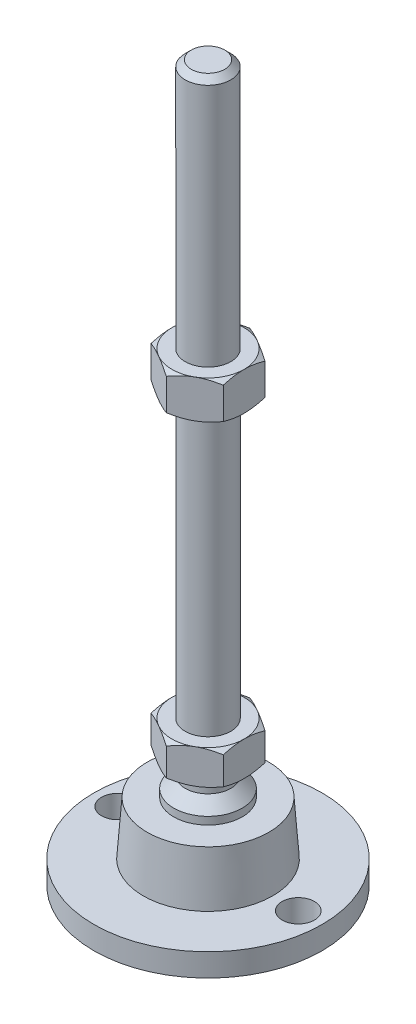
from build123d import *

# Parameters (mm, degrees)
EXTRUDE_1_DEPTH     = 9
EXTRUDE_2_DEPTH     = 10
SKETCH_5_R          = 4.25
CUT_EXTRUDE_1_DEPTH = 7


with BuildPart() as part:
    # Эскиз1 → Повернуть1 (revolve)
    with BuildSketch(Plane.XY, mode=Mode.PRIVATE) as revolve_1_sk:
        Polygon((0, 0), (-30, 0), (-30, 6), (-17, 6), (-16, 20), (-9, 20), (-9, 22), (-6, 25), (-6, 29), (-6, 38), (-6, 186.4), (-4.4, 188), (0, 188), align=None)
    revolve(revolve_1_sk.sketch.rotate(Axis((0, 0, 0), (0, 1, 0)), 180), axis=Axis((0, 0, 0), (0, 1, 0)))  # turned: the seam where the file's is

    # Эскиз2 → Бобышка-Вытянуть1 (add)
    with BuildSketch(Plane(origin=(0, 29, 0), x_dir=(1, 0, 0), z_dir=(0, 1, 0))):
        Polygon((0, 10.969655115), (-9.5, 5.484827557), (-9.5, -5.484827557), (0, -10.969655115), (9.5, -5.484827557), (9.5, 5.484827557), align=None)
    extrude(amount=EXTRUDE_1_DEPTH)

    # Эскиз3 → Бобышка-Вытянуть2 (add)
    with BuildSketch(Plane(origin=(0, 112.2, 0), x_dir=(1, 0, 0), z_dir=(0, 1, 0))):
        Polygon((9.5, 5.484827557), (0, 10.969655115), (-9.5, 5.484827557), (-9.5, -5.484827557), (0, -10.969655115), (9.5, -5.484827557), align=None)
    extrude(amount=EXTRUDE_2_DEPTH)

    # Эскиз4 → Вырез-Повернуть2 (revolve, cut)
    with BuildSketch(Plane.XY, mode=Mode.PRIVATE) as cut_revolve_2_sk:
        Polygon((-18.160254038, 122.2), (-9.5, 122.2), (-18.160254038, 117.2), align=None)
        Polygon((-18.160254038, 112.2), (-18.160254038, 117.2), (-9.5, 112.2), align=None)
        Polygon((-17.294228634, 38), (-17.294228634, 33.5), (-9.5, 38), align=None)
        Polygon((-17.294228634, 33.5), (-17.294228634, 29), (-9.5, 29), align=None)
    revolve(cut_revolve_2_sk.sketch.rotate(Axis((0, 188, 0), (0, -1, 0)), 180), axis=Axis((0, 188, 0), (0, -1, 0)), mode=Mode.SUBTRACT)  # turned: the seam where the file's is

    # Эскиз5 → Вырез-Вытянуть1 (cut, through all)
    with BuildSketch(Plane(origin=(0, 6, 0), x_dir=(1, 0, 0), z_dir=(0, 1, 0))):
        with Locations(Location((-23.75, 0, 0), (0, 0, 180))):  # turned: the seam where the file's is
            Circle(SKETCH_5_R)
        with Locations(Location((23.75, 0, 0), (0, 0, 180))):  # turned: the seam where the file's is
            Circle(SKETCH_5_R)
    extrude(amount=-CUT_EXTRUDE_1_DEPTH, mode=Mode.SUBTRACT)


solid = part.part
